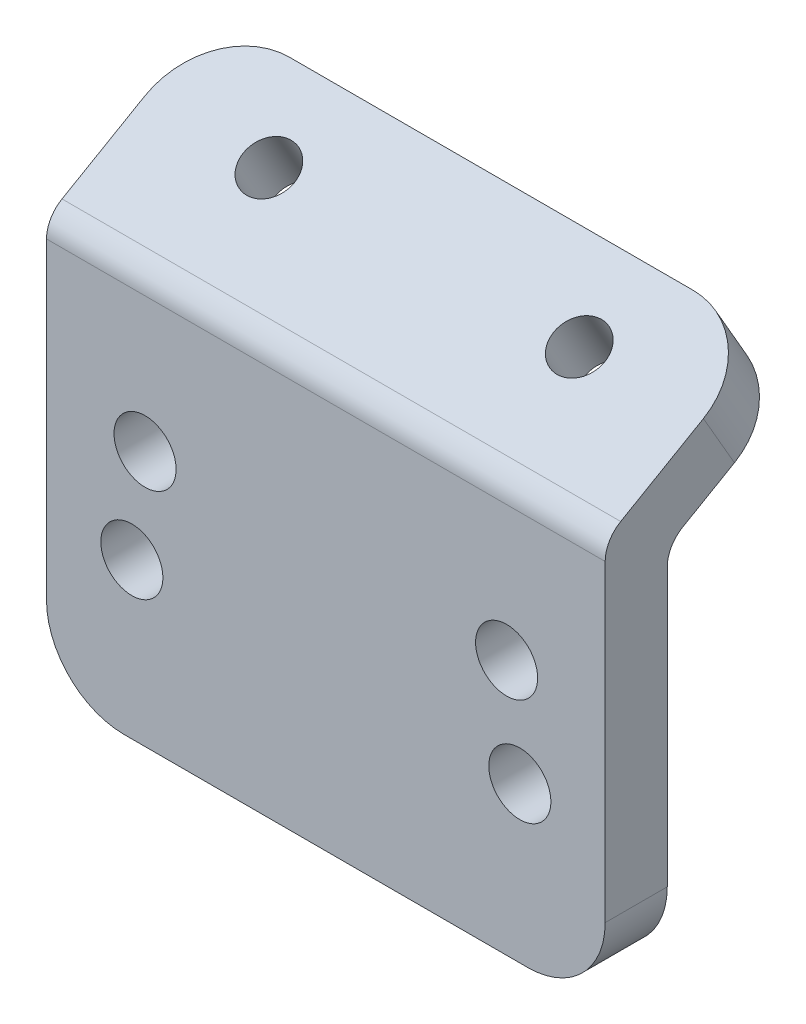
from build123d import *

# Parameters (mm, degrees)
ESQUISSE1_W                  = 36
ESQUISSE1_H                  = 24
BOSS_EXTRU_1_DEPTH           = 4
ESQUISSE2_R                  = 2
ENL_V_MAT_EXTRU_1_DEPTH      = 1
ENL_V_MAT_EXTRU_1_DEPTH_BACK = 5
BOSS_EXTRU_2_DEPTH           = 36
ESQUISSE4_R                  = 1.65
ENL_V_MAT_EXTRU_2_DEPTH      = 26.11473671
ENL_V_MAT_EXTRU_2_DEPTH_BACK = 10.330127019
CONG_2_R                     = 5
CONG_3_R                     = 2


with BuildPart() as part:
    # Esquisse1 → Boss.-Extru.1 (new body)
    with BuildSketch(Plane.XY):
        with Locations((18, 12)):
            Rectangle(ESQUISSE1_W, ESQUISSE1_H)
    extrude(amount=BOSS_EXTRU_1_DEPTH)

    # Esquisse2 → Enlèv. mat.-Extru.1 (cut, two sides)
    with BuildSketch(Plane.XY.offset(4)) as enl_v_mat_extru_1_sk:
        with Locations((5.5, 10)):
            Circle(ESQUISSE2_R)
        with Locations((30.5, 10)):
            Circle(ESQUISSE2_R)
        with Locations((29.648145657, 16.470476128)):
            Circle(ESQUISSE2_R)
        with Locations((6.351854343, 16.470476128)):
            Circle(ESQUISSE2_R)
    extrude(amount=ENL_V_MAT_EXTRU_1_DEPTH, mode=Mode.SUBTRACT)
    extrude(enl_v_mat_extru_1_sk.sketch, amount=-ENL_V_MAT_EXTRU_1_DEPTH_BACK, mode=Mode.SUBTRACT)

    # Esquisse3 → Boss.-Extru.2 (add)
    with BuildSketch(Plane(origin=(36, 0, 0), x_dir=(0, 0, -1), z_dir=(1, 0, 0))):
        Polygon((0, 24), (8.660254038, 29), (6.660254038, 32.464101615), (-4, 26.309401077), (-4, 24), align=None)
    extrude(amount=-BOSS_EXTRU_2_DEPTH)

    # Esquisse4 → Enlèv. mat.-Extru.2 (cut, two sides)
    with BuildSketch(Plane(origin=(0, 18, 10.392304845), x_dir=(1, 0, 0), z_dir=(0, -0.866025404, -0.5))) as enl_v_mat_extru_2_sk:
        with Locations((8, -17)):
            Circle(ESQUISSE4_R)
        with Locations((28, -17)):
            Circle(ESQUISSE4_R)
    extrude(amount=ENL_V_MAT_EXTRU_2_DEPTH, mode=Mode.SUBTRACT)
    extrude(enl_v_mat_extru_2_sk.sketch, amount=-ENL_V_MAT_EXTRU_2_DEPTH_BACK, mode=Mode.SUBTRACT)

    # Congé2
    cong_2_edges = [part.edges().sort_by_distance(p)[0] for p in [
        (0, 30.732050808, -7.660254038),
        (36, 30.732050808, -7.660254038),
        (36, 0, 2),
        (0, 0, 2),
    ]]
    fillet(cong_2_edges, radius=CONG_2_R)

    # Congé3
    cong_3_edges = [part.edges().sort_by_distance(p)[0] for p in [
        (18, 26.309401077, 4),
        (18, 24, 0),
    ]]
    fillet(cong_3_edges, radius=CONG_3_R)


solid = part.part
